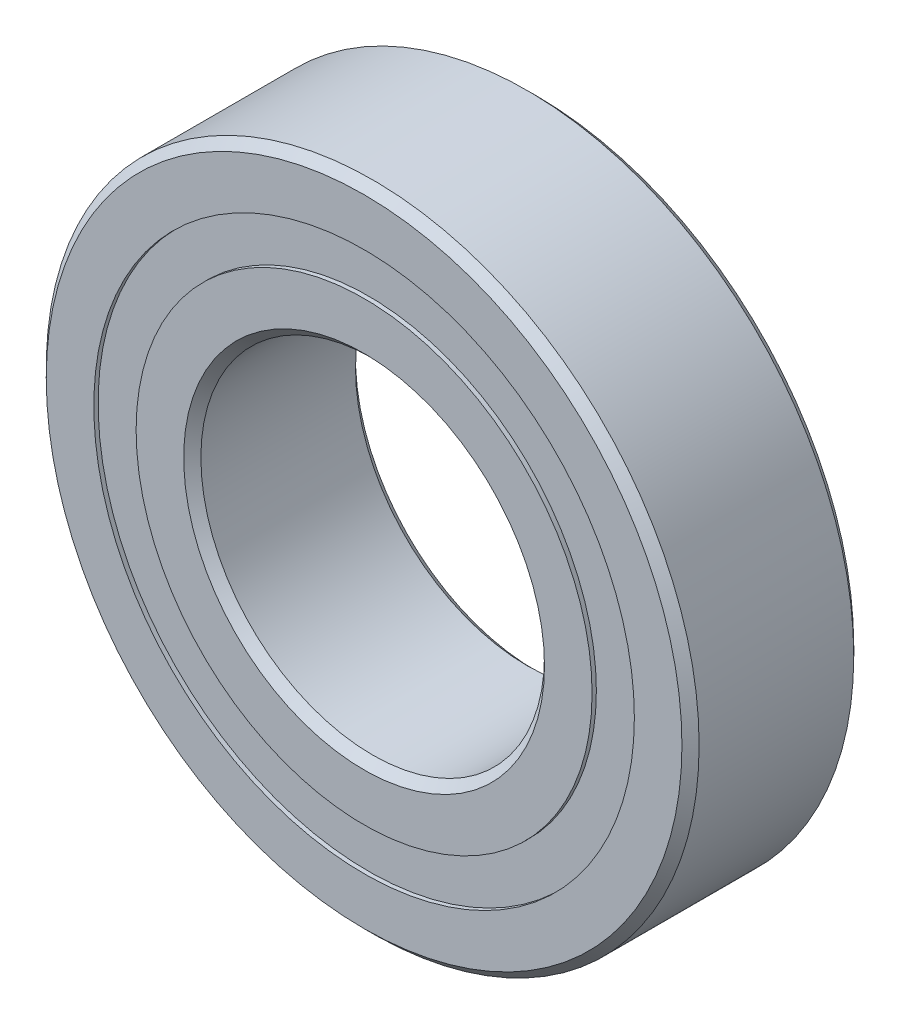
from build123d import *

# Parameters (mm, degrees)
CIRPATTERN1_COUNT = 12
SKETCH5_W         = 1.104855864
SKETCH5_H         = 1.23076923


with BuildPart() as part:
    # Sketch1 → Revolve1 (revolve)
    with BuildSketch(Plane(origin=(0, 0, 0), x_dir=(0, 0, -1), z_dir=(1, 0, 0))):
        with BuildLine():
            Line((2.25, 9.5), (-2.25, 9.5))
            Line((-2.25, 9.5), (-2.5, 9.25))
            Line((-2.5, 9.25), (-2.5, 7.865384615))
            Line((-2.5, 7.865384615), (-1.111111111, 7.865384615))
            ThreePointArc((-1.111111111, 7.865384615), (0, 8.520144136), (1.111111111, 7.865384615))
            Line((1.111111111, 7.865384615), (2.5, 7.865384615))
            Line((2.5, 7.865384615), (2.5, 9.25))
            Line((2.5, 9.25), (2.25, 9.5))
        make_face()
    revolve(axis=Axis((0, 0, 2.5), (0, 0, -1)))


with BuildPart() as body_2:
    # Sketch3 → Revolve3 (revolve)
    with BuildSketch(Plane(origin=(0, 0, 0), x_dir=(0, 0, -1), z_dir=(1, 0, 0))):
        with BuildLine():
            Line((-2.5, 6.634615385), (-1.111111111, 6.634615385))
            ThreePointArc((-1.111111111, 6.634615385), (0, 5.979855864), (1.111111111, 6.634615385))
            Line((1.111111111, 6.634615385), (2.5, 6.634615385))
            Line((2.5, 6.634615385), (2.5, 5.25))
            Line((2.5, 5.25), (2.25, 5))
            Line((2.25, 5), (-2.25, 5))
            Line((-2.25, 5), (-2.5, 5.25))
            Line((-2.5, 5.25), (-2.5, 6.634615385))
        make_face()
    revolve(axis=Axis((0, 0, 2.5), (0, 0, -1)))


with BuildPart() as body_3:
    # Sketch4 → Revolve4 (revolve)
    with BuildSketch(Plane(origin=(0, 0, 0), x_dir=(0, 0, -1), z_dir=(1, 0, 0))):
        with BuildLine():
            Line((-1.270144136, 7.25), (1.270144136, 7.25))
            ThreePointArc((1.270144136, 7.25), (0, 8.520144136), (-1.270144136, 7.25))
        make_face()
    revolve(axis=Axis((0, 7.25, 1.270144136), (0, 0, -1)))


with BuildPart() as cirpattern1_1:
    # CirPattern1: pattern copy
    add(body_3.part.rotate(Axis((0, 0, 0), (0, 0, 1)), 1 * 360 / CIRPATTERN1_COUNT))


with BuildPart() as cirpattern1_2:
    # CirPattern1: pattern copy
    add(body_3.part.rotate(Axis((0, 0, 0), (0, 0, 1)), 2 * 360 / CIRPATTERN1_COUNT))


with BuildPart() as cirpattern1_3:
    # CirPattern1: pattern copy
    add(body_3.part.rotate(Axis((0, 0, 0), (0, 0, 1)), 3 * 360 / CIRPATTERN1_COUNT))


with BuildPart() as cirpattern1_4:
    # CirPattern1: pattern copy
    add(body_3.part.rotate(Axis((0, 0, 0), (0, 0, 1)), 4 * 360 / CIRPATTERN1_COUNT))


with BuildPart() as cirpattern1_5:
    # CirPattern1: pattern copy
    add(body_3.part.rotate(Axis((0, 0, 0), (0, 0, 1)), 5 * 360 / CIRPATTERN1_COUNT))


with BuildPart() as cirpattern1_6:
    # CirPattern1: pattern copy
    add(body_3.part.rotate(Axis((0, 0, 0), (0, 0, 1)), 6 * 360 / CIRPATTERN1_COUNT))


with BuildPart() as cirpattern1_7:
    # CirPattern1: pattern copy
    add(body_3.part.rotate(Axis((0, 0, 0), (0, 0, 1)), 7 * 360 / CIRPATTERN1_COUNT))


with BuildPart() as cirpattern1_8:
    # CirPattern1: pattern copy
    add(body_3.part.rotate(Axis((0, 0, 0), (0, 0, 1)), 8 * 360 / CIRPATTERN1_COUNT))


with BuildPart() as cirpattern1_9:
    # CirPattern1: pattern copy
    add(body_3.part.rotate(Axis((0, 0, 0), (0, 0, 1)), 9 * 360 / CIRPATTERN1_COUNT))


with BuildPart() as cirpattern1_10:
    # CirPattern1: pattern copy
    add(body_3.part.rotate(Axis((0, 0, 0), (0, 0, 1)), 10 * 360 / CIRPATTERN1_COUNT))


with BuildPart() as cirpattern1_11:
    # CirPattern1: pattern copy
    add(body_3.part.rotate(Axis((0, 0, 0), (0, 0, 1)), 11 * 360 / CIRPATTERN1_COUNT))


with BuildPart() as body_15:
    # Sketch5 → Revolve5 (revolve)
    with BuildSketch(Plane(origin=(0, 0, 0), x_dir=(0, 0, -1), z_dir=(1, 0, 0))):
        with Locations((-1.822572068, 7.25)):
            Rectangle(SKETCH5_W, SKETCH5_H)
        with Locations((1.822572068, 7.25)):
            Rectangle(SKETCH5_W, SKETCH5_H)
    revolve(axis=Axis((0, 0, 2.5), (0, 0, -1)))


solid = Compound([part.part, body_2.part, body_3.part, cirpattern1_1.part, cirpattern1_2.part, cirpattern1_3.part, cirpattern1_4.part, cirpattern1_5.part, cirpattern1_6.part, cirpattern1_7.part, cirpattern1_8.part, cirpattern1_9.part, cirpattern1_10.part, cirpattern1_11.part, body_15.part])
